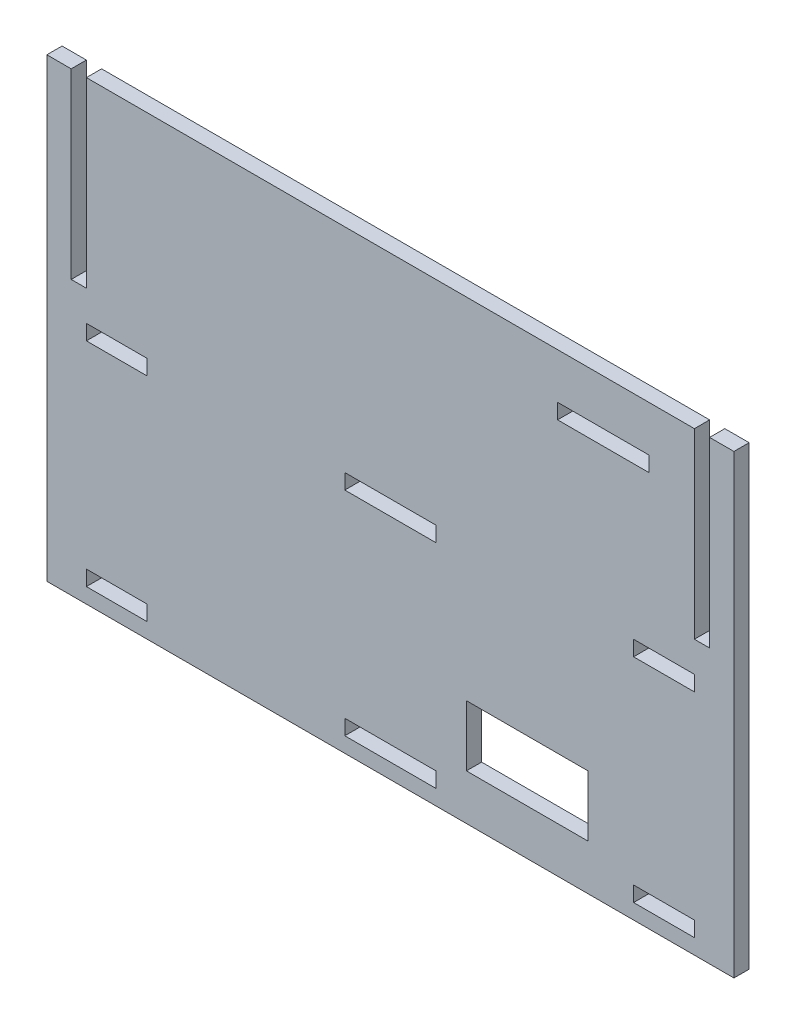
from build123d import *

# Parameters (mm, degrees)
ESQUISSE1_W        = 20
ESQUISSE1_H        = 5
ESQUISSE1_W_2      = 40
ESQUISSE1_H_2      = 20
ESQUISSE1_W_3      = 30
BOSS_EXTRU_1_DEPTH = 5


with BuildPart() as part:
    # Esquisse1 → Boss.-Extru.1 (new body)
    with BuildSketch(Plane.XY):
        Polygon((-100, 150), (100, 150), (100, 90), (105, 90), (105, 150), (113, 150), (113, 0), (-113, 0), (-113, 150), (-105, 150), (-105, 90), (-100, 90), align=None)
        with Locations((90, 7.5)):
            Rectangle(ESQUISSE1_W, ESQUISSE1_H, mode=Mode.SUBTRACT)
        with Locations((90, 77.5)):
            Rectangle(ESQUISSE1_W, ESQUISSE1_H, mode=Mode.SUBTRACT)
        Polygon((-15, 5), (15, 5), (15, 10), (0, 10), (-15, 10), align=None, mode=Mode.SUBTRACT)
        Polygon((-15, 80), (0, 80), (15, 80), (15, 75), (-15, 75), align=None, mode=Mode.SUBTRACT)
        with Locations((-90, 7.5)):
            Rectangle(ESQUISSE1_W, ESQUISSE1_H, mode=Mode.SUBTRACT)
        with Locations((-90, 77.5)):
            Rectangle(ESQUISSE1_W, ESQUISSE1_H, mode=Mode.SUBTRACT)
        with Locations((45, 25)):
            Rectangle(ESQUISSE1_W_2, ESQUISSE1_H_2, mode=Mode.SUBTRACT)
        with Locations((70, 132.5)):
            Rectangle(ESQUISSE1_W_3, ESQUISSE1_H, mode=Mode.SUBTRACT)
    extrude(amount=BOSS_EXTRU_1_DEPTH)


solid = part.part
